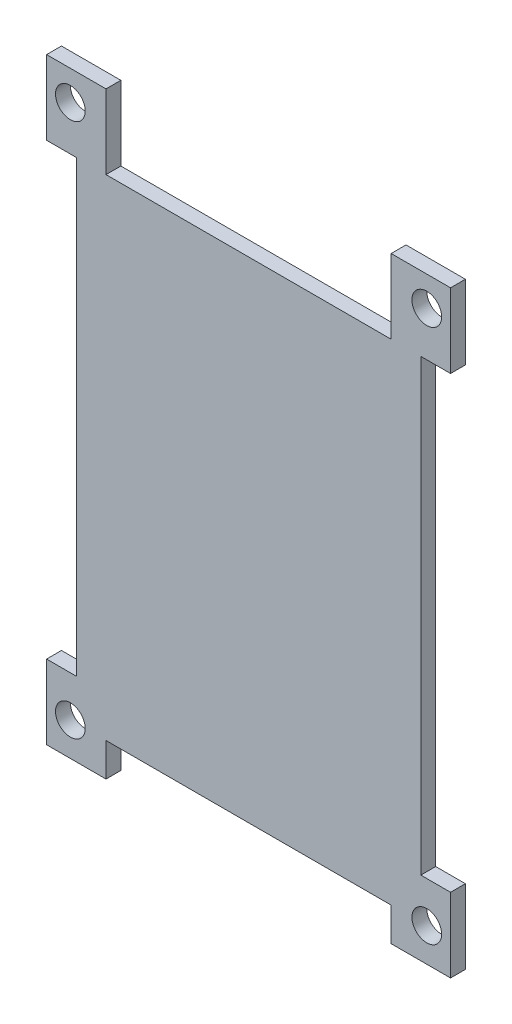
from build123d import *

# Parameters (mm, degrees)
EXTRUSION1_DEPTH        = 2
ESQUISSE2_R             = 2
ENL_V_MAT_EXTRU_1_DEPTH = 3


with BuildPart() as part:
    # Esquisse1 → Extrusion1 (new body)
    with BuildSketch(Plane.XY):
        Polygon((-19.2, 33), (19.2, 33), (19.2, 43), (27.2, 43), (27.2, 33), (23.2, 33), (23.2, -27.5), (27.2, -27.5), (27.2, -37.5), (19.2, -37.5), (19.2, -33), (-19.2, -33), (-19.2, -37.5), (-27.2, -37.5), (-27.2, -27.5), (-23.2, -27.5), (-23.2, 33), (-27.2, 33), (-27.2, 43), (-19.2, 43), align=None)
    extrude(amount=EXTRUSION1_DEPTH)

    # Esquisse2 → Enlèv. mat.-Extru.1 (cut, through all)
    with BuildSketch(Plane.XY.offset(2)):
        with Locations((-24, 39)):
            Circle(ESQUISSE2_R)
        with Locations((24, 39)):
            Circle(ESQUISSE2_R)
        with Locations((-24, -33)):
            Circle(ESQUISSE2_R)
        with Locations((24, -33)):
            Circle(ESQUISSE2_R)
    extrude(amount=-ENL_V_MAT_EXTRU_1_DEPTH, mode=Mode.SUBTRACT)


solid = part.part
